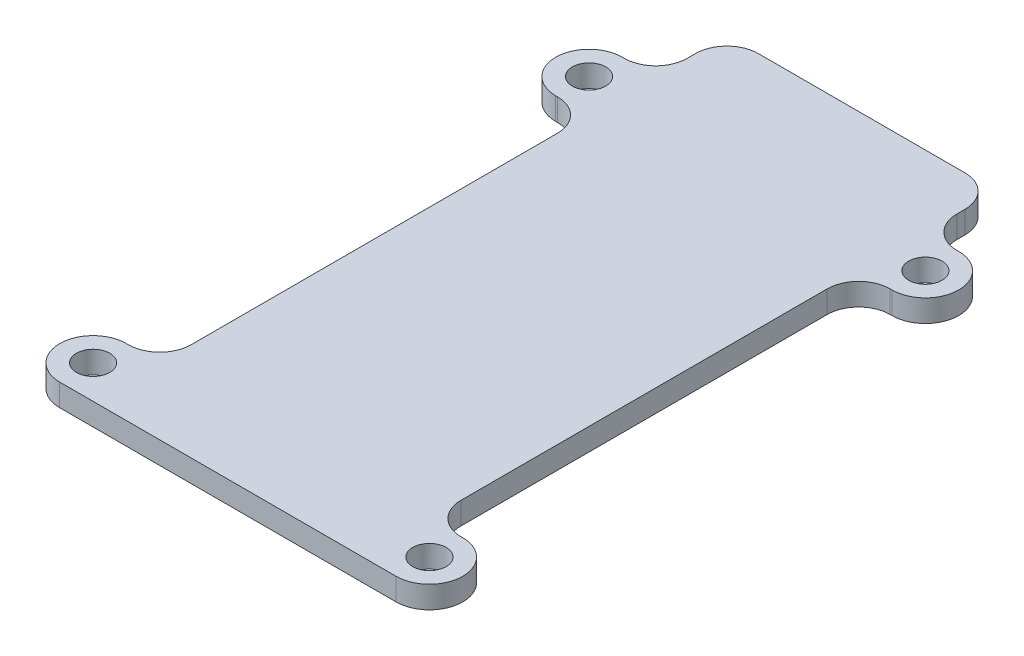
from build123d import *

# Parameters (mm, degrees)
SKETCH1_R           = 4.7625
BOSS_EXTRUDE1_DEPTH = 6.35


with BuildPart() as part:
    # Sketch1 → Boss-Extrude1 (new body)
    with BuildSketch(Plane(origin=(0, 0, 0), x_dir=(1, 0, 0), z_dir=(0, 1, 0))):
        with BuildLine():
            Line((0, 132.63), (0, 28.05))
            ThreePointArc((0, 28.05), (-2.636038969, 21.686038969), (-9, 19.05))
            Line((-9, 19.05), (-9.525, 19.05))
            ThreePointArc((-9.525, 19.05), (-19.05, 9.525), (-9.525, 0))
            Line((-9.525, 0), (0, 0))
            Line((0, 0), (77, 0))
            Line((77, 0), (86.525, 0))
            ThreePointArc((86.525, 0), (96.05, 9.525), (86.525, 19.05))
            Line((86.525, 19.05), (86, 19.05))
            ThreePointArc((86, 19.05), (79.636038969, 21.686038969), (77, 28.05))
            Line((77, 28.05), (77, 132.63))
            ThreePointArc((77, 132.63), (79.636038969, 138.993961031), (86, 141.63))
            Line((86, 141.63), (86.525, 141.63))
            ThreePointArc((86.525, 141.63), (96.05, 151.155), (86.525, 160.68))
            Line((86.525, 160.68), (86, 160.68))
            ThreePointArc((86, 160.68), (79.636038969, 163.316038969), (77, 169.68))
            Line((77, 169.68), (77, 172))
            ThreePointArc((77, 172), (74.363961031, 178.363961031), (68, 181))
            Line((68, 181), (9, 181))
            ThreePointArc((9, 181), (2.636038969, 178.363961031), (0, 172))
            Line((0, 172), (0, 169.68))
            ThreePointArc((0, 169.68), (-2.636038969, 163.316038969), (-9, 160.68))
            Line((-9, 160.68), (-9.525, 160.68))
            ThreePointArc((-9.525, 160.68), (-19.05, 151.155), (-9.525, 141.63))
            Line((-9.525, 141.63), (-9, 141.63))
            ThreePointArc((-9, 141.63), (-2.636038969, 138.993961031), (0, 132.63))
        make_face()
        with Locations((86.525, 151.155)):
            Circle(SKETCH1_R, mode=Mode.SUBTRACT)
        with Locations((-9.525, 151.155)):
            Circle(SKETCH1_R, mode=Mode.SUBTRACT)
        with Locations((-9.525, 9.525)):
            Circle(SKETCH1_R, mode=Mode.SUBTRACT)
        with Locations((86.525, 9.525)):
            Circle(SKETCH1_R, mode=Mode.SUBTRACT)
    extrude(amount=BOSS_EXTRUDE1_DEPTH)


solid = part.part
